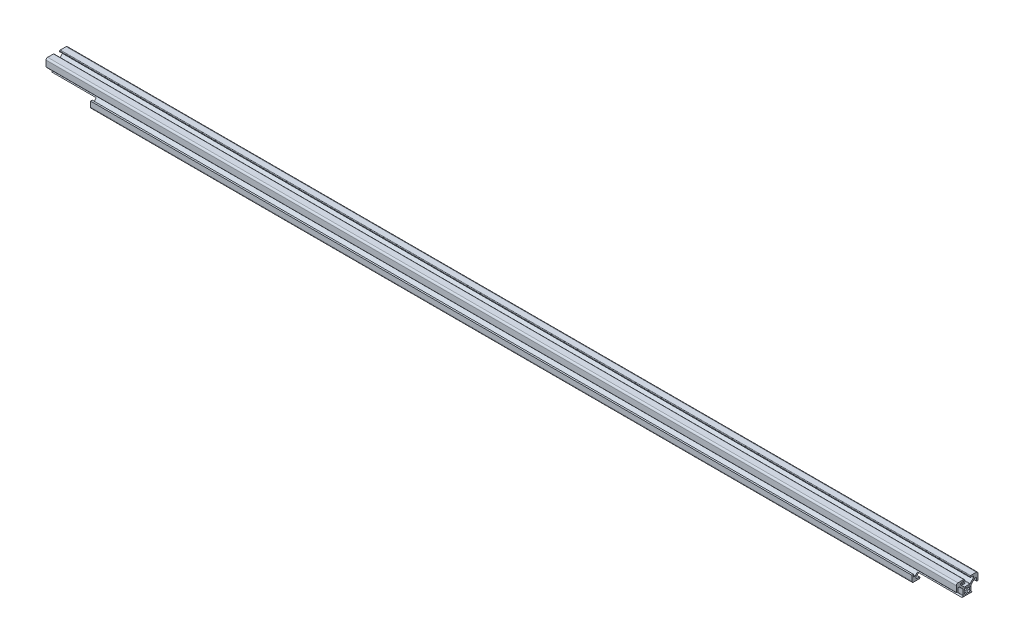
from build123d import *

# Parameters (mm, degrees)
C_PROGRAM_FILES_SOLIDWORKS_CORP_SOLIDWOR_DEPTH = 838.4
SKETCH125_W                                    = 41
SKETCH125_H                                    = 6.345
CUT_EXTRUDE2_DEPTH                             = 839.703038271
CUT_EXTRUDE3_START                             = -838.4
CUT_EXTRUDE3_DEPTH                             = 838.4
SKETCH128_R                                    = 1.5
CUT_EXTRUDE4_DEPTH                             = 839.582565836


with BuildPart() as part:
    # Sketch122 → C_PROGRAM FILES_SOLIDWORKS CORP_SOLIDWOR (new body)
    with BuildSketch(Plane.YZ):
        with BuildLine():
            Line((9.895192042, 3.57078143), (9.411192042, 3.57078143))
            ThreePointArc((9.411192042, 3.57078143), (9.051981797, 3.719571185), (8.903192042, 4.07878143))
            Line((8.903192042, 4.07878143), (8.903192042, 6.42778143))
            ThreePointArc((8.903192042, 6.42778143), (8.754402286, 6.786991675), (8.395192042, 6.93578143))
            Line((8.395192042, 6.93578143), (7.669272703, 6.93578143))
            ThreePointArc((7.669272703, 6.93578143), (7.474869519, 6.897112233), (7.310062458, 6.786991675))
            Line((7.310062458, 6.786991675), (4.206981797, 3.683911014))
            ThreePointArc((4.206981797, 3.683911014), (4.096861239, 3.519103952), (4.058192042, 3.324700769))
            Line((4.058192042, 3.324700769), (4.058192042, -1.443137908))
            ThreePointArc((4.058192042, -1.443137908), (4.096861239, -1.637541092), (4.206981797, -1.802348153))
            Line((4.206981797, -1.802348153), (7.310062458, -4.905428815))
            ThreePointArc((7.310062458, -4.905428815), (7.474869519, -5.015549372), (7.669272703, -5.05421857))
            Line((7.669272703, -5.05421857), (8.395192042, -5.05421857))
            ThreePointArc((8.395192042, -5.05421857), (8.754402286, -4.905428815), (8.903192042, -4.54621857))
            Line((8.903192042, -4.54621857), (8.903192042, -2.19721857))
            ThreePointArc((8.903192042, -2.19721857), (9.051981797, -1.838008325), (9.411192042, -1.68921857))
            Line((9.411192042, -1.68921857), (9.895192042, -1.68921857))
            ThreePointArc((9.895192042, -1.68921857), (10.254402286, -1.838008325), (10.403192042, -2.19721857))
            Line((10.403192042, -2.19721857), (10.403192042, -7.55921857))
            ThreePointArc((10.403192042, -7.55921857), (9.963852213, -8.619878742), (8.903192042, -9.05921857))
            Line((8.903192042, -9.05921857), (3.541192042, -9.05921857))
            ThreePointArc((3.541192042, -9.05921857), (3.181981797, -8.910428815), (3.033192042, -8.55121857))
            Line((3.033192042, -8.55121857), (3.033192042, -8.06721857))
            ThreePointArc((3.033192042, -8.06721857), (3.181981797, -7.708008325), (3.541192042, -7.55921857))
            Line((3.541192042, -7.55921857), (5.890192042, -7.55921857))
            ThreePointArc((5.890192042, -7.55921857), (6.249402286, -7.410428815), (6.398192042, -7.05121857))
            Line((6.398192042, -7.05121857), (6.398192042, -6.325299231))
            ThreePointArc((6.398192042, -6.325299231), (6.359522844, -6.130896048), (6.249402286, -5.966088986))
            Line((6.249402286, -5.966088986), (3.146321625, -2.863008325))
            ThreePointArc((3.146321625, -2.863008325), (2.981514564, -2.752887767), (2.78711138, -2.71421857))
            Line((2.78711138, -2.71421857), (-1.980727297, -2.71421857))
            ThreePointArc((-1.980727297, -2.71421857), (-2.175130481, -2.752887767), (-2.339937542, -2.863008325))
            Line((-2.339937542, -2.863008325), (-5.443018203, -5.966088986))
            ThreePointArc((-5.443018203, -5.966088986), (-5.553138761, -6.130896048), (-5.591807958, -6.325299231))
            Line((-5.591807958, -6.325299231), (-5.591807958, -7.05121857))
            ThreePointArc((-5.591807958, -7.05121857), (-5.443018203, -7.410428815), (-5.083807958, -7.55921857))
            Line((-5.083807958, -7.55921857), (-2.734807958, -7.55921857))
            ThreePointArc((-2.734807958, -7.55921857), (-2.375597714, -7.708008325), (-2.226807958, -8.06721857))
            Line((-2.226807958, -8.06721857), (-2.226807958, -8.55121857))
            ThreePointArc((-2.226807958, -8.55121857), (-2.375597714, -8.910428815), (-2.734807958, -9.05921857))
            Line((-2.734807958, -9.05921857), (-8.096807958, -9.05921857))
            ThreePointArc((-8.096807958, -9.05921857), (-9.15746813, -8.619878742), (-9.596807958, -7.55921857))
            Line((-9.596807958, -7.55921857), (-9.596807958, -2.19721857))
            ThreePointArc((-9.596807958, -2.19721857), (-9.448018203, -1.838008325), (-9.088807958, -1.68921857))
            Line((-9.088807958, -1.68921857), (-8.604807958, -1.68921857))
            ThreePointArc((-8.604807958, -1.68921857), (-8.245597714, -1.838008325), (-8.096807958, -2.19721857))
            Line((-8.096807958, -2.19721857), (-8.096807958, -4.54621857))
            ThreePointArc((-8.096807958, -4.54621857), (-7.948018203, -4.905428815), (-7.588807958, -5.05421857))
            Line((-7.588807958, -5.05421857), (-6.86288862, -5.05421857))
            ThreePointArc((-6.86288862, -5.05421857), (-6.668485436, -5.015549372), (-6.503678375, -4.905428815))
            Line((-6.503678375, -4.905428815), (-3.400597714, -1.802348153))
            ThreePointArc((-3.400597714, -1.802348153), (-3.290477156, -1.637541092), (-3.251807958, -1.443137908))
            Line((-3.251807958, -1.443137908), (-3.251807958, 3.324700769))
            ThreePointArc((-3.251807958, 3.324700769), (-3.290477156, 3.519103952), (-3.400597714, 3.683911014))
            Line((-3.400597714, 3.683911014), (-6.503678375, 6.786991675))
            ThreePointArc((-6.503678375, 6.786991675), (-6.668485436, 6.897112233), (-6.86288862, 6.93578143))
            Line((-6.86288862, 6.93578143), (-7.588807958, 6.93578143))
            ThreePointArc((-7.588807958, 6.93578143), (-7.948018203, 6.786991675), (-8.096807958, 6.42778143))
            Line((-8.096807958, 6.42778143), (-8.096807958, 4.07878143))
            ThreePointArc((-8.096807958, 4.07878143), (-8.245597714, 3.719571185), (-8.604807958, 3.57078143))
            Line((-8.604807958, 3.57078143), (-9.088807958, 3.57078143))
            ThreePointArc((-9.088807958, 3.57078143), (-9.448018203, 3.719571185), (-9.596807958, 4.07878143))
            Line((-9.596807958, 4.07878143), (-9.596807958, 9.44078143))
            ThreePointArc((-9.596807958, 9.44078143), (-9.15746813, 10.501441602), (-8.096807958, 10.94078143))
            Line((-8.096807958, 10.94078143), (-2.734807958, 10.94078143))
            ThreePointArc((-2.734807958, 10.94078143), (-2.375597714, 10.791991675), (-2.226807958, 10.43278143))
            Line((-2.226807958, 10.43278143), (-2.226807958, 9.94878143))
            ThreePointArc((-2.226807958, 9.94878143), (-2.375597714, 9.589571185), (-2.734807958, 9.44078143))
            Line((-2.734807958, 9.44078143), (-5.083807958, 9.44078143))
            ThreePointArc((-5.083807958, 9.44078143), (-5.443018203, 9.291991675), (-5.591807958, 8.93278143))
            Line((-5.591807958, 8.93278143), (-5.591807958, 8.206862092))
            ThreePointArc((-5.591807958, 8.206862092), (-5.553138761, 8.012458908), (-5.443018203, 7.847651847))
            Line((-5.443018203, 7.847651847), (-2.339937542, 4.744571185))
            ThreePointArc((-2.339937542, 4.744571185), (-2.175130481, 4.634450628), (-1.980727297, 4.59578143))
            Line((-1.980727297, 4.59578143), (2.78711138, 4.59578143))
            ThreePointArc((2.78711138, 4.59578143), (2.981514564, 4.634450628), (3.146321625, 4.744571185))
            Line((3.146321625, 4.744571185), (6.249402286, 7.847651847))
            ThreePointArc((6.249402286, 7.847651847), (6.359522844, 8.012458908), (6.398192042, 8.206862092))
            Line((6.398192042, 8.206862092), (6.398192042, 8.93278143))
            ThreePointArc((6.398192042, 8.93278143), (6.249402286, 9.291991675), (5.890192042, 9.44078143))
            Line((5.890192042, 9.44078143), (3.541192042, 9.44078143))
            ThreePointArc((3.541192042, 9.44078143), (3.181981797, 9.589571185), (3.033192042, 9.94878143))
            Line((3.033192042, 9.94878143), (3.033192042, 10.43278143))
            ThreePointArc((3.033192042, 10.43278143), (3.181981797, 10.791991675), (3.541192042, 10.94078143))
            Line((3.541192042, 10.94078143), (8.903192042, 10.94078143))
            ThreePointArc((8.903192042, 10.94078143), (9.963852213, 10.501441602), (10.403192042, 9.44078143))
            Line((10.403192042, 9.44078143), (10.403192042, 4.07878143))
            ThreePointArc((10.403192042, 4.07878143), (10.254402286, 3.719571185), (9.895192042, 3.57078143))
        make_face()
        with BuildLine():
            Line((2.528092885, -1.363724536), (2.707698008, -1.184119414))
            ThreePointArc((2.707698008, -1.184119414), (2.909130058, -0.415686381), (2.338325548, 0.136804712))
            ThreePointArc((2.338325548, 0.136804712), (2.498692042, 0.94078143), (2.338325548, 1.744758148))
            ThreePointArc((2.338325548, 1.744758148), (2.909130058, 2.297249241), (2.707698008, 3.065682274))
            Line((2.707698008, 3.065682274), (2.528092885, 3.245287396))
            ThreePointArc((2.528092885, 3.245287396), (1.759659852, 3.446719447), (1.20716876, 2.875914936))
            ThreePointArc((1.20716876, 2.875914936), (0.403192042, 3.03628143), (-0.400784676, 2.875914936))
            ThreePointArc((-0.400784676, 2.875914936), (-0.953275769, 3.446719447), (-1.721708802, 3.245287396))
            Line((-1.721708802, 3.245287396), (-1.901313925, 3.065682274))
            ThreePointArc((-1.901313925, 3.065682274), (-2.102745975, 2.297249241), (-1.531941465, 1.744758148))
            ThreePointArc((-1.531941465, 1.744758148), (-1.692307958, 0.94078143), (-1.531941465, 0.136804712))
            ThreePointArc((-1.531941465, 0.136804712), (-2.102745975, -0.415686381), (-1.901313925, -1.184119414))
            Line((-1.901313925, -1.184119414), (-1.721708802, -1.363724536))
            ThreePointArc((-1.721708802, -1.363724536), (-0.953275769, -1.565156587), (-0.400784676, -0.994352076))
            ThreePointArc((-0.400784676, -0.994352076), (0.403192042, -1.15471857), (1.20716876, -0.994352076))
            ThreePointArc((1.20716876, -0.994352076), (1.759659852, -1.565156587), (2.528092885, -1.363724536))
        make_face(mode=Mode.SUBTRACT)
    extrude(amount=C_PROGRAM_FILES_SOLIDWORKS_CORP_SOLIDWOR_DEPTH)

    # Sketch125 → Cut-Extrude2 (cut, through all)
    with BuildSketch(Plane(origin=(0, 0, -9.05921857), x_dir=(-1, 0, 0), z_dir=(0, 0, -1))):
        with Locations((-817.9, -6.424307958)):
            Rectangle(SKETCH125_W, SKETCH125_H)
        with Locations((-20.5, -6.424307958)):
            Rectangle(SKETCH125_W, SKETCH125_H)
    extrude(amount=-CUT_EXTRUDE2_DEPTH, mode=Mode.SUBTRACT)

    # Sketch127 → Cut-Extrude3 (cut)
    with BuildSketch(Plane.ZY.offset(CUT_EXTRUDE3_START)):
        with BuildLine():
            Line((-9.05921857, -2.734807958), (-9.05921857, -3.251807958))
            Line((-9.05921857, -3.251807958), (-7.55921857, -3.251807958))
            Line((-7.55921857, -3.251807958), (-7.55921857, -2.734807958))
            ThreePointArc((-7.55921857, -2.734807958), (-7.708008325, -2.375597714), (-8.06721857, -2.226807958))
            Line((-8.06721857, -2.226807958), (-8.55121857, -2.226807958))
            ThreePointArc((-8.55121857, -2.226807958), (-8.910428815, -2.375597714), (-9.05921857, -2.734807958))
        make_face()
        with BuildLine():
            Line((9.44078143, -2.734807958), (9.44078143, -3.251807958))
            Line((9.44078143, -3.251807958), (10.94078143, -3.251807958))
            Line((10.94078143, -3.251807958), (10.94078143, -2.734807958))
            ThreePointArc((10.94078143, -2.734807958), (10.791991675, -2.375597714), (10.43278143, -2.226807958))
            Line((10.43278143, -2.226807958), (9.94878143, -2.226807958))
            ThreePointArc((9.94878143, -2.226807958), (9.589571185, -2.375597714), (9.44078143, -2.734807958))
        make_face()
    cut_extrude3 = extrude(amount=CUT_EXTRUDE3_DEPTH, mode=Mode.SUBTRACT)

    # Sketch128 → Cut-Extrude4 (cut, through all)
    with BuildSketch(Plane.XZ.offset(3.251807958)):
        with Locations(Location((4, 0.94078143, 0), (0, 0, 270))):
            Circle(SKETCH128_R)
        with Locations(Location((19, 0.94078143, 0), (0, 0, 270))):
            Circle(SKETCH128_R)
        with Locations(Location((34, 0.94078143, 0), (0, 0, 270))):
            Circle(SKETCH128_R)
    cut_extrude4 = extrude(amount=-CUT_EXTRUDE4_DEPTH, mode=Mode.SUBTRACT)

    # Mirror1: Cut-Extrude3, Cut-Extrude4 across plane
    add(cut_extrude3.mirror(Plane(origin=(419.2, 0, 0), x_dir=(0, 0, 1), z_dir=(1, 0, 0))), mode=Mode.SUBTRACT)
    add(cut_extrude4.mirror(Plane(origin=(419.2, 0, 0), x_dir=(0, 0, 1), z_dir=(1, 0, 0))), mode=Mode.SUBTRACT)


solid = part.part
